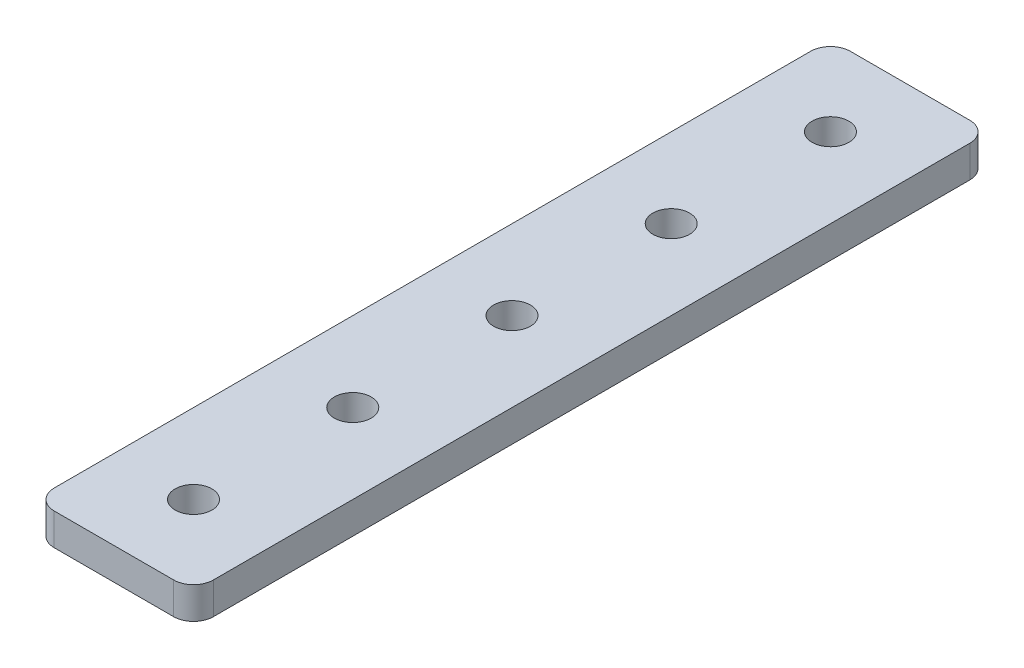
from build123d import *

# Parameters (mm, degrees)
SKETCH1_R               = 1.85
BOSS_EXTRUDE1_DEPTH     = 3.2
CUT_EXTRUDE1_DEPTH      = 4.2
CUT_EXTRUDE1_DEPTH_BACK = 1
FILLET1_R               = 2


with BuildPart() as part:
    # Sketch1 → Boss-Extrude1 (new body)
    with BuildSketch(Plane(origin=(0, 3.2, 0), x_dir=(1, 0, 0), z_dir=(0, 1, 0))):
        with BuildLine():
            Line((8, 2), (8, 286))
            ThreePointArc((8, 286), (7.414213562, 287.414213562), (6, 288))
            Line((6, 288), (-6, 288))
            ThreePointArc((-6, 288), (-7.414213562, 287.414213562), (-8, 286))
            Line((-8, 286), (-8, 2))
            ThreePointArc((-8, 2), (-7.414213562, 0.585786438), (-6, 0))
            Line((-6, 0), (6, 0))
            ThreePointArc((6, 0), (7.414213562, 0.585786438), (8, 2))
        make_face()
        with Locations((0, 280)):
            Circle(SKETCH1_R, mode=Mode.SUBTRACT)
        with Locations((0, 264)):
            Circle(SKETCH1_R, mode=Mode.SUBTRACT)
        with Locations((0, 248)):
            Circle(SKETCH1_R, mode=Mode.SUBTRACT)
        with Locations((0, 232)):
            Circle(SKETCH1_R, mode=Mode.SUBTRACT)
        with Locations((0, 216)):
            Circle(SKETCH1_R, mode=Mode.SUBTRACT)
        with Locations((0, 200)):
            Circle(SKETCH1_R, mode=Mode.SUBTRACT)
        with Locations((0, 184)):
            Circle(SKETCH1_R, mode=Mode.SUBTRACT)
        with Locations((0, 168)):
            Circle(SKETCH1_R, mode=Mode.SUBTRACT)
        with Locations((0, 152)):
            Circle(SKETCH1_R, mode=Mode.SUBTRACT)
        with Locations((0, 136)):
            Circle(SKETCH1_R, mode=Mode.SUBTRACT)
        with Locations((0, 120)):
            Circle(SKETCH1_R, mode=Mode.SUBTRACT)
        with Locations((0, 104)):
            Circle(SKETCH1_R, mode=Mode.SUBTRACT)
        with Locations((0, 88)):
            Circle(SKETCH1_R, mode=Mode.SUBTRACT)
        with Locations((0, 72)):
            Circle(SKETCH1_R, mode=Mode.SUBTRACT)
        with Locations((0, 56)):
            Circle(SKETCH1_R, mode=Mode.SUBTRACT)
        with Locations((0, 40)):
            Circle(SKETCH1_R, mode=Mode.SUBTRACT)
        with Locations((0, 24)):
            Circle(SKETCH1_R, mode=Mode.SUBTRACT)
        with Locations((0, 8)):
            Circle(SKETCH1_R, mode=Mode.SUBTRACT)
    extrude(amount=-BOSS_EXTRUDE1_DEPTH)

    # Sketch2 → Cut-Extrude1 (cut, two sides)
    with BuildSketch(Plane(origin=(0, 0, 0), x_dir=(1, 0, 0), z_dir=(0, 1, 0))) as cut_extrude1_sk:
        Polygon((-474.979607439, 80), (-38.646772996, 80), (26.442528892, 80), (462.775363335, 80), (462.775363335, 952.665668885), (-474.979607439, 952.665668885), align=None)
    extrude(amount=CUT_EXTRUDE1_DEPTH, mode=Mode.SUBTRACT)
    extrude(cut_extrude1_sk.sketch, amount=-CUT_EXTRUDE1_DEPTH_BACK, mode=Mode.SUBTRACT)

    # Fillet1
    fillet1_edges = [part.edges().sort_by_distance(p)[0] for p in [
        (8, 1.6, -80),
        (-8, 1.6, -80),
    ]]
    fillet(fillet1_edges, radius=FILLET1_R)


solid = part.part
